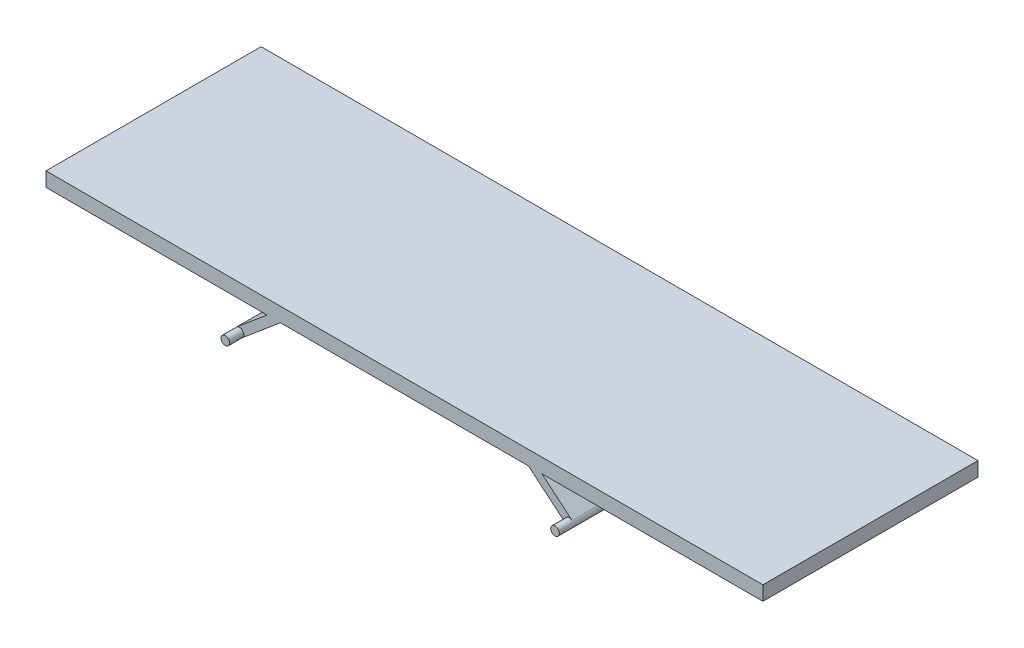
from build123d import *

# Parameters (mm, degrees)
BOSS_EXTRUDE1_DEPTH = 300
SKETCH2_R           = 6
BOSS_EXTRUDE2_DEPTH = 20


with BuildPart() as part:
    # Sketch1 → Boss-Extrude1 (new body)
    with BuildSketch(Plane.XY):
        with BuildLine():
            Line((-233.856725658, -45.403733341), (-191.664199257, -10))
            Line((-191.664199257, -10), (-500, -10))
            Line((-500, -10), (-500, 10))
            Line((-500, 10), (500, 10))
            Line((500, 10), (500, -10))
            Line((500, -10), (191.664199257, -10))
            Line((191.664199257, -10), (233.856725658, -45.403733341))
            ThreePointArc((233.856725658, -45.403733341), (234.596266659, -53.856725658), (226.143274342, -54.596266659))
            Line((226.143274342, -54.596266659), (172.995513335, -10))
            Line((172.995513335, -10), (-172.995513335, -10))
            Line((-172.995513335, -10), (-226.143274342, -54.596266659))
            ThreePointArc((-226.143274342, -54.596266659), (-234.596266659, -53.856725658), (-233.856725658, -45.403733341))
        make_face()
    extrude(amount=BOSS_EXTRUDE1_DEPTH)

    # Sketch2 → Boss-Extrude2 (add)
    with BuildSketch(Plane.XY.offset(300)):
        with Locations((-230, -50)):
            Circle(SKETCH2_R)
        with Locations((230, -50)):
            Circle(SKETCH2_R)
    extrude(amount=BOSS_EXTRUDE2_DEPTH)


solid = part.part
